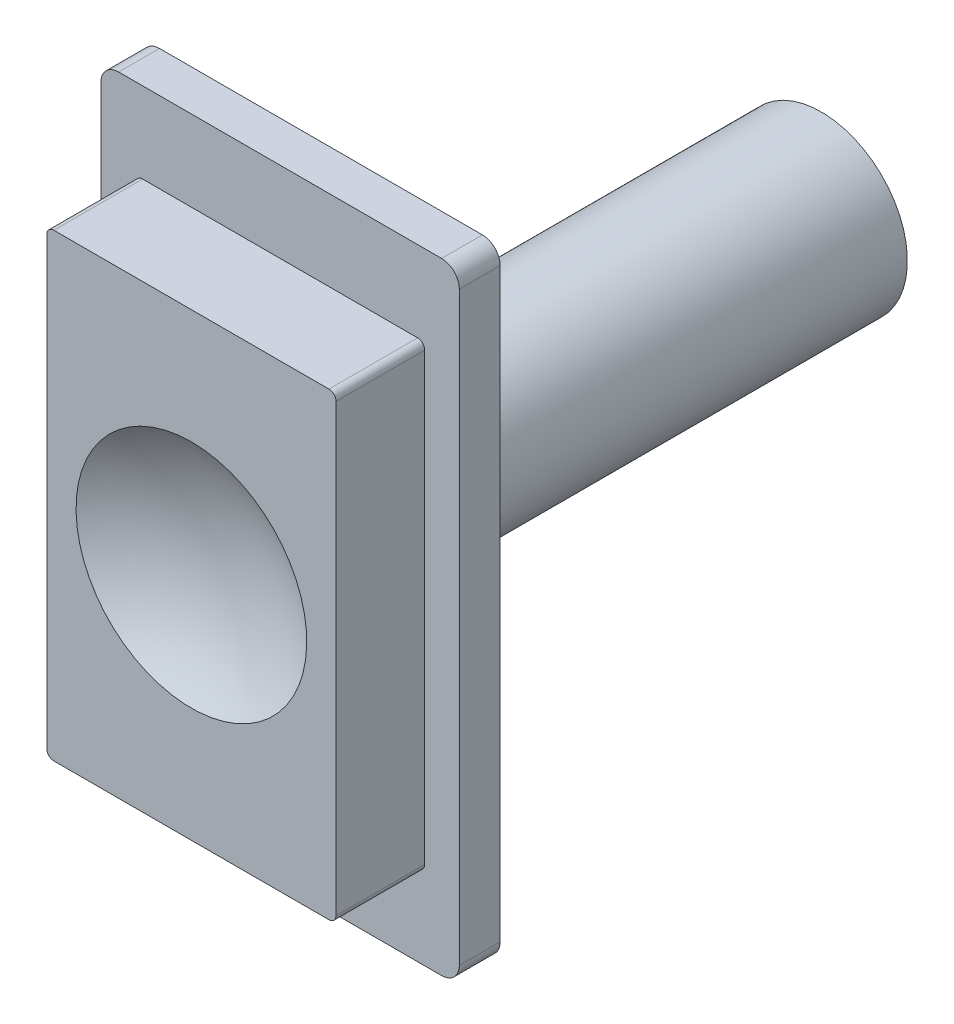
from build123d import *

# Parameters (mm, degrees)
SKETCH1_W           = 35
SKETCH1_H           = 20.2
BOSS_EXTRUDE1_DEPTH = 2.3
SKETCH2_W           = 16.3
SKETCH2_H           = 25.9
BOSS_EXTRUDE2_DEPTH = 5
FILLET2_R           = 1
FILLET3_R           = 0.4
SKETCH5_R           = 4.85
BOSS_EXTRUDE3_DEPTH = 28.2
CUT_EXTRUDE3_DEPTH  = 16


with BuildPart() as part:
    # Sketch1 → Boss-Extrude1 (new body)
    with BuildSketch(Plane(origin=(0, 0, 0), x_dir=(0, 1, 0), z_dir=(0, 0, 1))):
        Rectangle(SKETCH1_W, SKETCH1_H)
    extrude(amount=BOSS_EXTRUDE1_DEPTH)

    # Sketch2 → Boss-Extrude2 (add)
    with BuildSketch(Plane.XY.offset(2.3)):
        Rectangle(SKETCH2_W, SKETCH2_H)
    extrude(amount=BOSS_EXTRUDE2_DEPTH)

    # Sketch4 → Cut-Revolve1 (revolve, cut)
    with BuildSketch(Plane.YZ):
        with BuildLine():
            Line((0, 7.3), (-6.5, 7.3))
            ThreePointArc((-6.5, 7.3), (-3.398426688, 5.817613265), (0, 5.3))
            Line((0, 5.3), (0, 7.3))
        make_face()
    revolve(axis=Axis((0, 0, 0), (0, 0, 1)), mode=Mode.SUBTRACT)

    # Fillet2
    fillet2_edges = [part.edges().sort_by_distance(p)[0] for p in [
        (10.1, 17.5, 1.15),
        (10.1, -17.5, 1.15),
        (-10.1, -17.5, 1.15),
        (-10.1, 17.5, 1.15),
    ]]
    fillet(fillet2_edges, radius=FILLET2_R)

    # Fillet3
    fillet3_edges = [part.edges().sort_by_distance(p)[0] for p in [
        (8.15, -12.95, 4.8),
        (8.15, 12.95, 4.8),
        (-8.15, 12.95, 4.8),
        (-8.15, -12.95, 4.8),
    ]]
    fillet(fillet3_edges, radius=FILLET3_R)

    # Sketch5 → Boss-Extrude3 (add)
    with BuildSketch(Plane(origin=(0, 0, 0), x_dir=(1, 0, 0), z_dir=(0, 0, -1))):
        Circle(SKETCH5_R)
    extrude(amount=BOSS_EXTRUDE3_DEPTH)

    # Sketch6 → Cut-Extrude3 (cut)
    with BuildSketch(Plane(origin=(0, 0, -28.2), x_dir=(1, 0, 0), z_dir=(0, 0, -1))):
        with BuildLine():
            Line((-0.5, 3.15), (-0.5, 2.244994432))
            ThreePointArc((-0.5, 2.244994432), (0, 2.3), (0.5, 2.244994432))
            Line((0.5, 2.244994432), (0.5, 3.15))
            Line((0.5, 3.15), (-0.5, 3.15))
        make_face()
        with BuildLine():
            Line((0.5, 1.45), (-0.5, 1.45))
            Line((-0.5, 1.45), (-0.5, 2.244994432))
            ThreePointArc((-0.5, 2.244994432), (-2.3, 0), (-0.5, -2.244994432))
            Line((-0.5, -2.244994432), (-0.5, -1.45))
            Line((-0.5, -1.45), (0.5, -1.45))
            Line((0.5, -1.45), (0.5, -2.244994432))
            ThreePointArc((0.5, -2.244994432), (1.794435844, -1.438749457), (2.3, 0))
            ThreePointArc((2.3, 0), (1.794435844, 1.438749457), (0.5, 2.244994432))
            Line((0.5, 2.244994432), (0.5, 1.45))
        make_face()
        with BuildLine():
            ThreePointArc((0.5, -2.244994432), (0, -2.3), (-0.5, -2.244994432))
            Line((-0.5, -2.244994432), (-0.5, -3.15))
            Line((-0.5, -3.15), (0.5, -3.15))
            Line((0.5, -3.15), (0.5, -2.244994432))
        make_face()
        with BuildLine():
            Line((-0.5, 2.244994432), (-0.5, 1.45))
            Line((-0.5, 1.45), (0.5, 1.45))
            Line((0.5, 1.45), (0.5, 2.244994432))
            ThreePointArc((0.5, 2.244994432), (0, 2.3), (-0.5, 2.244994432))
        make_face()
        with BuildLine():
            Line((-0.5, -1.45), (-0.5, -2.244994432))
            ThreePointArc((-0.5, -2.244994432), (0, -2.3), (0.5, -2.244994432))
            Line((0.5, -2.244994432), (0.5, -1.45))
            Line((0.5, -1.45), (-0.5, -1.45))
        make_face()
    extrude(amount=-CUT_EXTRUDE3_DEPTH, mode=Mode.SUBTRACT)


solid = part.part
